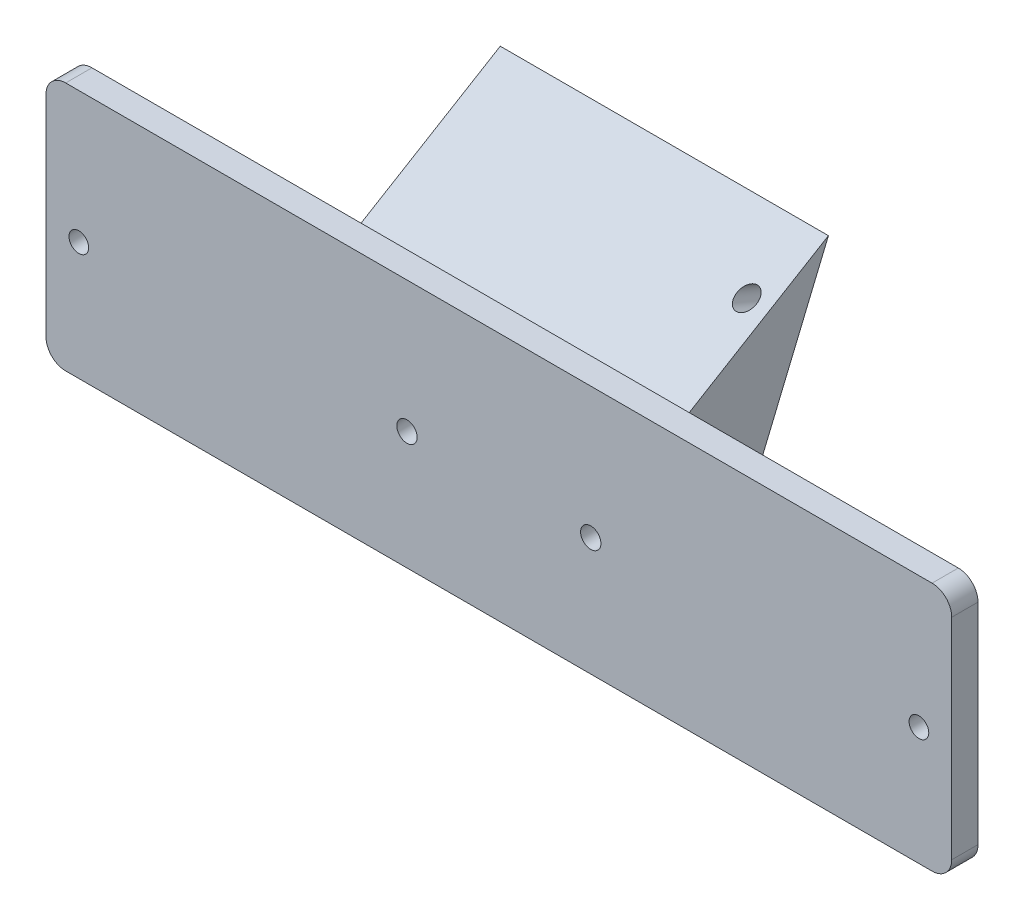
from build123d import *

# Parameters (mm, degrees)
SALIENTE_EXTRUIR1_DEPTH    = 4
CORTAR_EXTRUIR1_DEPTH      = 13
CORTAR_EXTRUIR1_DEPTH_BACK = 4
CROQUIS2_R                 = 1.5
SALIENTE_EXTRUIR5_DEPTH    = 94
CORTAR_EXTRUIR2_DEPTH      = 44
CORTAR_EXTRUIR3_DEPTH      = 44
CORTAR_EXTRUIR3_DEPTH_BACK = 44
CROQUIS10_R                = 1.55
CROQUIS15_R                = 4
CORTAR_EXTRUIR5_DEPTH      = 14
CROQUIS17_R                = 1.5
CORTAR_EXTRUIR6_DEPTH      = 16
CORTAR_EXTRUIR9_DEPTH      = 18
CORTAR_EXTRUIR9_DEPTH_BACK = 9
CROQUIS19_R                = 1.55


with BuildPart() as part:
    # Croquis1 → Saliente-Extruir1 (new body)
    with BuildSketch(Plane.XY):
        with BuildLine():
            Line((-66, -19), (66, -19))
            ThreePointArc((66, -19), (68.121320344, -18.121320344), (69, -16))
            Line((69, -16), (69, 16))
            ThreePointArc((69, 16), (68.121320344, 18.121320344), (66, 19))
            Line((66, 19), (-66, 19))
            ThreePointArc((-66, 19), (-68.121320344, 18.121320344), (-69, 16))
            Line((-69, 16), (-69, -16))
            ThreePointArc((-69, -16), (-68.121320344, -18.121320344), (-66, -19))
        make_face()
    extrude(amount=SALIENTE_EXTRUIR1_DEPTH)

    # Croquis2 → Cortar-Extruir1 (cut, two sides: drawn at the far end of the back side and taken through both)
    with BuildSketch(Plane.XY.offset(-CORTAR_EXTRUIR1_DEPTH_BACK)):
        with Locations((-64, -1)):
            Circle(CROQUIS2_R)
        with Locations((64, -1)):
            Circle(CROQUIS2_R)
    extrude(amount=CORTAR_EXTRUIR1_DEPTH + CORTAR_EXTRUIR1_DEPTH_BACK, mode=Mode.SUBTRACT)

    # Croquis4 → Saliente-Extruir5 (add)
    with BuildSketch(Plane(origin=(69, 0, 0), x_dir=(0, 0, -1), z_dir=(1, 0, 0))):
        Polygon((0, -19), (21.2115146, 31.745163793), (0, 19), align=None)
    extrude(amount=-SALIENTE_EXTRUIR5_DEPTH)

    # Croquis6 → Cortar-Extruir2 (cut)
    with BuildSketch(Plane(origin=(69, 0, 0), x_dir=(0, 0, -1), z_dir=(1, 0, 0))):
        Polygon((0, -19), (0, 19), (21.2115146, 31.745163793), align=None)
    extrude(amount=-CORTAR_EXTRUIR2_DEPTH, mode=Mode.SUBTRACT)

    # Croquis10 → Cortar-Extruir3 (cut, two sides: drawn at the far end of the back side and taken through both)
    with BuildSketch(Plane.XY.offset(4).offset(-CORTAR_EXTRUIR3_DEPTH_BACK)):
        with Locations((-14, -1)):
            Circle(CROQUIS10_R)
        with Locations((14, -1)):
            Circle(CROQUIS10_R)
    extrude(amount=CORTAR_EXTRUIR3_DEPTH + CORTAR_EXTRUIR3_DEPTH_BACK, mode=Mode.SUBTRACT)

    # Croquis15 → Cortar-Extruir5 (cut)
    with BuildSketch(Plane.XY):
        with Locations((14, -1)):
            Circle(CROQUIS15_R)
        with Locations((-14, -1)):
            Circle(CROQUIS15_R)
    extrude(amount=-CORTAR_EXTRUIR5_DEPTH, mode=Mode.SUBTRACT)

    # Croquis17 → Cortar-Extruir6 (cut)
    with BuildSketch(Plane(origin=(0, -2.825996258, -6.760745081), x_dir=(-1, 0, 0), z_dir=(0, -0.38566390181618804, -0.9226393416909523))):
        with Locations((-21.6, 28.969852508)):
            Circle(CROQUIS17_R)
    extrude(amount=-CORTAR_EXTRUIR6_DEPTH, mode=Mode.SUBTRACT)

    # Croquis19 → Cortar-Extruir9 (cut, two sides: drawn at the far end of the back side and taken through both)
    with BuildSketch(Plane(origin=(0, -2.825996258, -6.760745081), x_dir=(-1, 0, 0), z_dir=(0, -0.385663901816188, -0.9226393416909522)).offset(-CORTAR_EXTRUIR9_DEPTH_BACK)):
        with Locations((22, -4.530147492)):
            Circle(CROQUIS19_R)
        with Locations((-12, -4.530147492)):
            Circle(CROQUIS19_R)
    extrude(amount=CORTAR_EXTRUIR9_DEPTH + CORTAR_EXTRUIR9_DEPTH_BACK, mode=Mode.SUBTRACT)


solid = part.part
